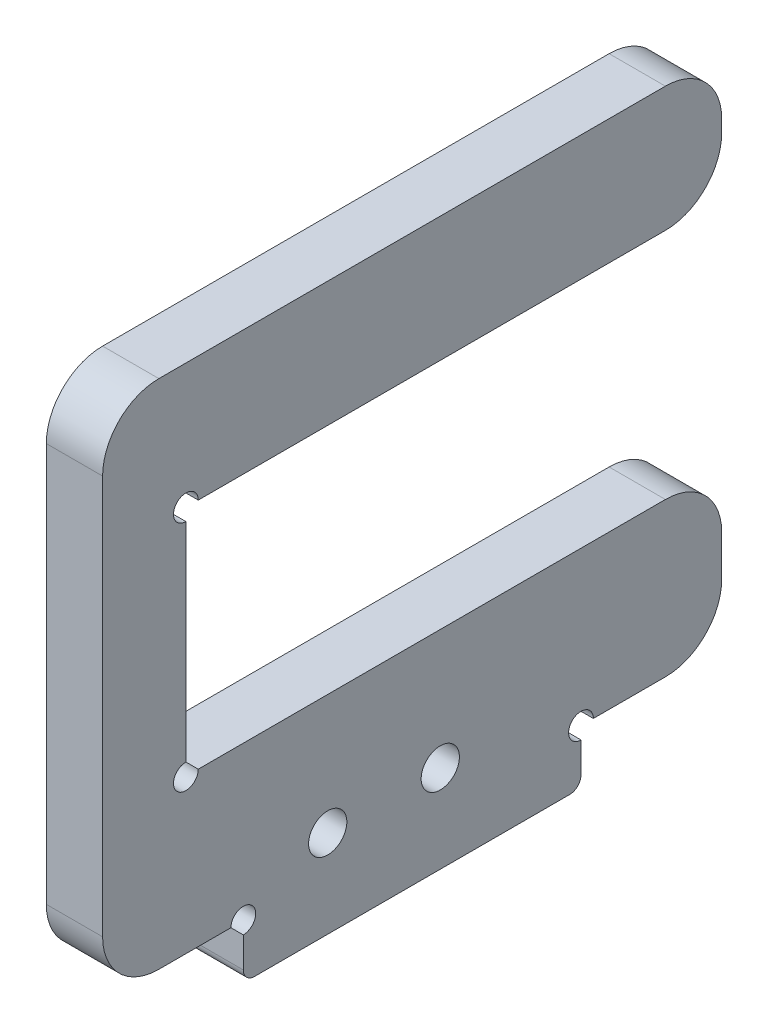
from build123d import *

# Parameters (mm, degrees)
SKETCH_1_W           = 55
SKETCH_1_H           = 45.45
SKETCH_1_W_2         = 40.2
SKETCH_1_H_2         = 20.7
EXTRUDE_1_DEPTH      = 5
SKETCH_2_W           = 30
SKETCH_2_H           = 4.8
EXTRUDE_2_DEPTH      = 5
SKETCH_3_R           = 1.1
CUT_EXTRUDE_1_DEPTH  = 5
FILLET_2_R           = 5
FILLET_3_R           = 1
M3_CLEARANCE_HOLE1_D = 3.4
SKETCH3_W            = 7.4
SKETCH3_H            = 20.7
CUT_EXTRUDE1_DEPTH   = 10
FILLET1_R            = 5


with BuildPart() as part:
    # 草图1 → 凸台-拉伸1 (new body)
    with BuildSketch(Plane(origin=(0, 0, 0), x_dir=(0, 0, -1), z_dir=(1, 0, 0))):
        with Locations((27.5, 22.725)):
            Rectangle(SKETCH_1_W, SKETCH_1_H)
        with Locations((27.5, 24)):
            Rectangle(SKETCH_1_W_2, SKETCH_1_H_2, mode=Mode.SUBTRACT)
    extrude(amount=EXTRUDE_1_DEPTH)

    # 草图2 → 凸台-拉伸2 (add)
    with BuildSketch(Plane.ZY):
        with Locations((-27.5, -2.4)):
            Rectangle(SKETCH_2_W, SKETCH_2_H)
    extrude(amount=-EXTRUDE_2_DEPTH)

    # 草图3 → 切除-拉伸1 (cut)
    with BuildSketch(Plane.ZY):
        with Locations((-42.5, 0)):
            Circle(SKETCH_3_R)
        with Locations((-12.5, 0)):
            Circle(SKETCH_3_R)
        with Locations((-7.4, 13.65)):
            Circle(SKETCH_3_R)
        with Locations((-7.4, 34.35)):
            Circle(SKETCH_3_R)
    extrude(amount=-CUT_EXTRUDE_1_DEPTH, mode=Mode.SUBTRACT)

    # 圆角2
    fillet_2_edges = [part.edges().sort_by_distance(p)[0] for p in [
        (2.5, 45.45, 0),
        (2.5, 45.45, -55),
        (2.5, 0, -55),
        (2.5, 0, 0),
    ]]
    fillet(fillet_2_edges, radius=FILLET_2_R)

    # 圆角3
    fillet_3_edges = [part.edges().sort_by_distance(p)[0] for p in [
        (2.5, -4.8, -42.5),
        (2.5, -4.8, -12.5),
    ]]
    fillet(fillet_3_edges, radius=FILLET_3_R)

    # M3 Clearance Hole1 (through all)
    with Locations(Plane.ZY):
        with Locations((-30, 3), (-20, 3)):
            Hole(M3_CLEARANCE_HOLE1_D / 2)

    # Sketch3 → Cut-Extrude1 (cut)
    with BuildSketch(Plane.ZY):
        with Locations((-51.3, 24)):
            Rectangle(SKETCH3_W, SKETCH3_H)
    extrude(amount=-CUT_EXTRUDE1_DEPTH, mode=Mode.SUBTRACT)

    # Fillet1
    fillet1_edges = [part.edges().sort_by_distance(p)[0] for p in [
        (2.5, 13.65, -55),
        (2.5, 34.35, -55),
    ]]
    fillet(fillet1_edges, radius=FILLET1_R)


solid = part.part
